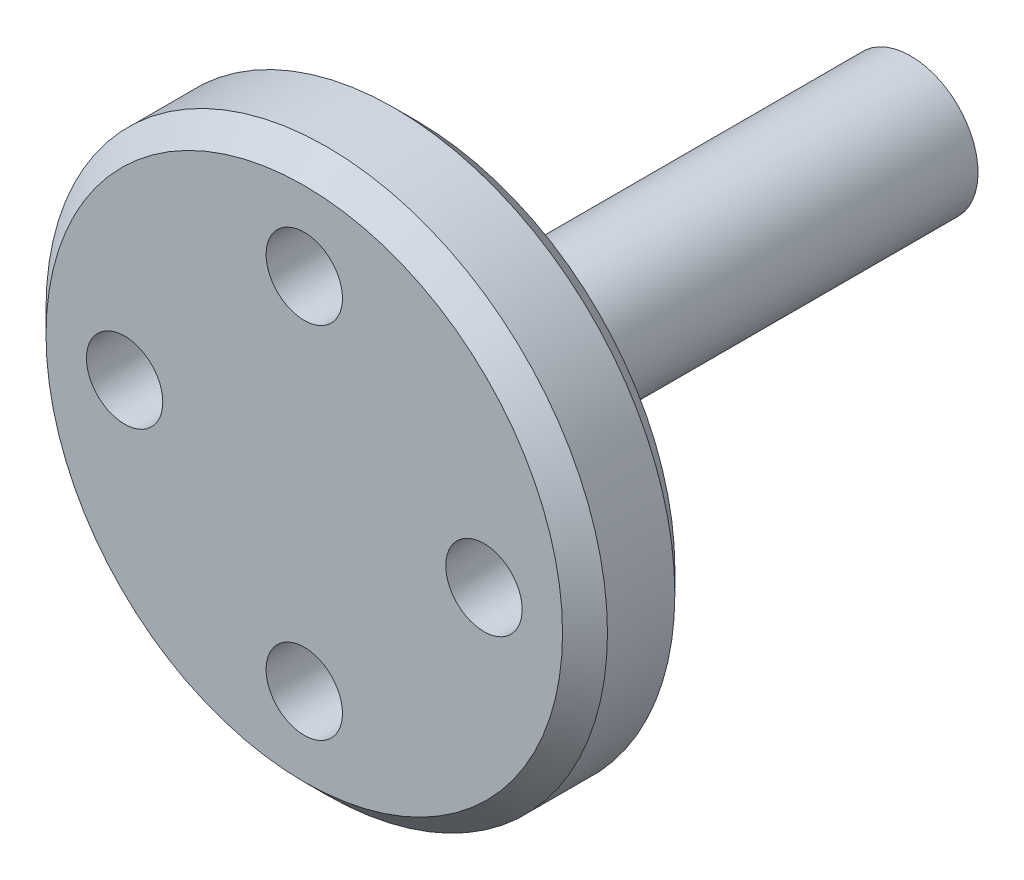
from build123d import *

# Parameters (mm, degrees)
M3_CLEARANCE_HOLE1_D = 3.4
CIRPATTERN1_COUNT    = 4
CHAMFER1_SIZE        = 1


with BuildPart() as part:
    # Sketch1 → Revolve1 (revolve)
    with BuildSketch(Plane(origin=(0, 0, 0), x_dir=(0, 0, -1), z_dir=(1, 0, 0))):
        Polygon((0, 0), (0, 12.5), (5, 12.5), (5, 3), (27, 3), (27, 0), align=None)
    revolve(axis=Axis((0, 0, -27), (0, 0, 1)))

    # M3 Clearance Hole1 (through all)
    with Locations(Plane(origin=(8, 0, 0), x_dir=(0, 1, 0), z_dir=(0, 0, 1))):
        with Locations((0, 0)):
            m3_clearance_hole1 = Hole(M3_CLEARANCE_HOLE1_D / 2)

    # CirPattern1: M3 Clearance Hole1 ×4 about axis
    cirpattern1_axis = Axis((0, 0, 0), (0, 0, 1))
    for i in range(1, CIRPATTERN1_COUNT):
        add(m3_clearance_hole1.rotate(cirpattern1_axis, i * 360 / CIRPATTERN1_COUNT), mode=Mode.SUBTRACT)

    # Chamfer1
    chamfer1_edges = [part.edges().sort_by_distance(p)[0] for p in [
        (0, -12.5, -5),
        (0, -12.5, 0),
    ]]
    chamfer(chamfer1_edges, length=CHAMFER1_SIZE)


solid = part.part
